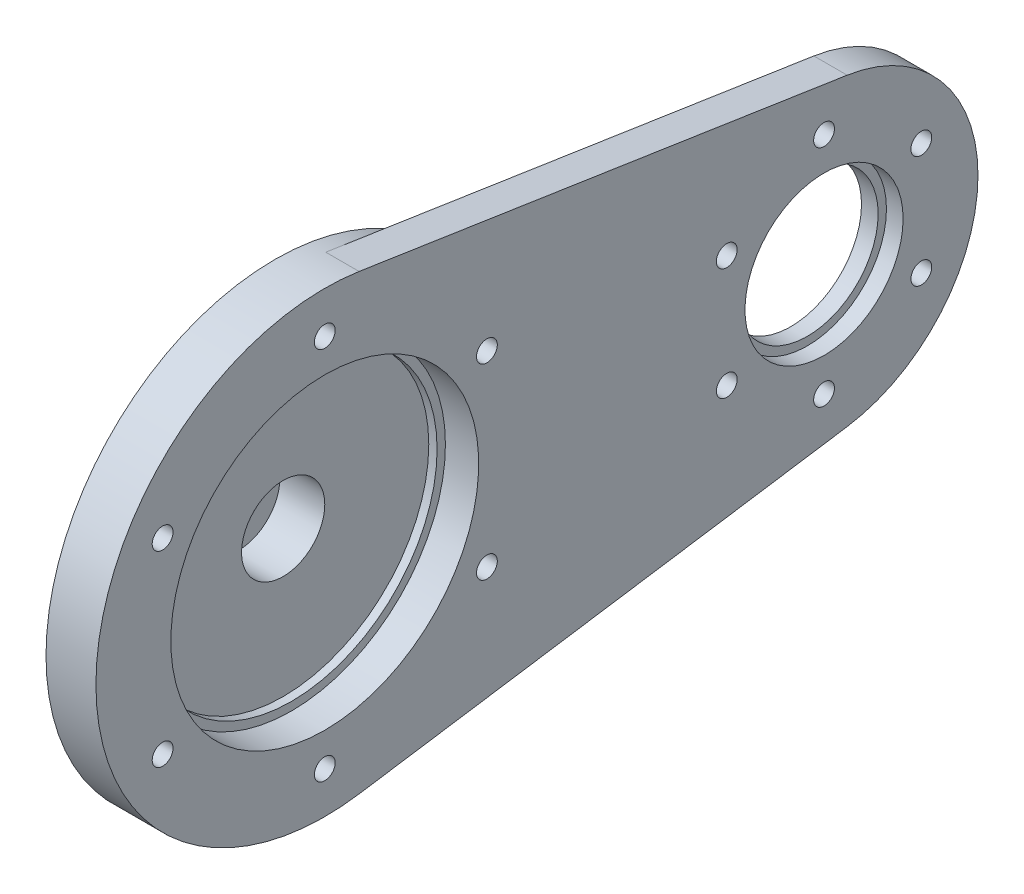
from build123d import *

# Parameters (mm, degrees)
SKETCH_3_R                   = 27.5
EXTRUDE_1_DEPTH              = 2
SKETCH_4_R                   = 27.5
SKETCH_4_R_2                 = 17.5
EXTRUDE_2_DEPTH              = 1
SKETCH_5_R                   = 27.5
SKETCH_5_R_2                 = 18.5
EXTRUDE_3_DEPTH              = 7
SKETCH_6_R                   = 27.5
SKETCH_6_R_2                 = 17.5
EXTRUDE_4_DEPTH              = 2
EXTRUDE_5_DEPTH              = 9
SKETCH_11_R                  = 8.5
CUT_EXTRUDE_3_DEPTH          = 111
SKETCH_12_R                  = 9.5
CUT_EXTRUDE_4_DEPTH          = 2.5
SKETCH_13_R                  = 9.5
EXTRUDE_6_DEPTH              = 5
SKETCH_17_W                  = 17.714059585
SKETCH_17_H                  = 64.604217311
CUT_EXTRUDE_5_DEPTH          = 1111
HOLE_WIZARD_M3_1_D           = 2.5
PATTERN_CIRCULAR_2_COUNT     = 6
HOLE_WIZARD_M3_2_D           = 2.5
PATTERN_CIRCULAR_3_COUNT     = 6
SKETCH_26_R                  = 27.5
SKETCH_26_R_2                = 25
CUT_EXTRUDE_6_DEPTH          = 1
FILLET_1_R                   = 0.1
PATTERN_CIRCULAR_4_COUNT     = 3
HOLE_WIZARD_M5_1_D           = 5.3
HOLE_WIZARD_M5_1_CBORE_D     = 10
HOLE_WIZARD_M5_1_CBORE_DEPTH = 5.4


with BuildPart() as part:
    # 스케치3 → 보스-돌출1 (new body)
    with BuildSketch(Plane(origin=(0, 0, 0), x_dir=(0, 0, -1), z_dir=(1, 0, 0))):
        Circle(SKETCH_3_R)
    extrude(amount=EXTRUDE_1_DEPTH)

    # 스케치4 → 보스-돌출2 (add)
    with BuildSketch(Plane(origin=(2, 0, 0), x_dir=(0, 0, -1), z_dir=(1, 0, 0))):
        Circle(SKETCH_4_R)
        Circle(SKETCH_4_R_2, mode=Mode.SUBTRACT)
    extrude(amount=EXTRUDE_2_DEPTH)

    # 스케치5 → 보스-돌출3 (add)
    with BuildSketch(Plane(origin=(3, 0, 0), x_dir=(0, 0, -1), z_dir=(1, 0, 0))):
        Circle(SKETCH_5_R)
        Circle(SKETCH_5_R_2, mode=Mode.SUBTRACT)
    extrude(amount=EXTRUDE_3_DEPTH)

    # 스케치6 → 보스-돌출4 (add)
    with BuildSketch(Plane(origin=(10, 0, 0), x_dir=(0, 0, -1), z_dir=(1, 0, 0))):
        Circle(SKETCH_6_R)
        Circle(SKETCH_6_R_2, mode=Mode.SUBTRACT)
    extrude(amount=EXTRUDE_4_DEPTH)

    # 스케치10 → 보스-돌출5 (add)
    with BuildSketch(Plane(origin=(12, 0, 0), x_dir=(0, 0, -1), z_dir=(1, 0, 0))):
        with BuildLine():
            Line((4.125, 27.188864908), (62.775, 18.290690938))
            ThreePointArc((62.775, 18.290690938), (78.5, 0), (62.775, -18.290690938))
            Line((62.775, -18.290690938), (4.125, -27.188864908))
            ThreePointArc((4.125, -27.188864908), (27.5, 0), (4.125, 27.188864908))
        make_face()
    extrude(amount=-EXTRUDE_5_DEPTH)

    # 스케치11 → 컷-돌출3 (cut, symmetric)
    with BuildSketch(Plane(origin=(7.5, 0, 0), x_dir=(0, 0, -1), z_dir=(1, 0, 0))):
        with Locations((60, 0)):
            Circle(SKETCH_11_R)
    extrude(amount=CUT_EXTRUDE_3_DEPTH, both=True, mode=Mode.SUBTRACT)

    # 스케치12 → 컷-돌출4 (cut, symmetric)
    with BuildSketch(Plane(origin=(7.5, 0, 0), x_dir=(0, 0, -1), z_dir=(1, 0, 0))):
        with Locations((60, 0)):
            Circle(SKETCH_12_R)
    extrude(amount=CUT_EXTRUDE_4_DEPTH, both=True, mode=Mode.SUBTRACT)

    # 스케치13 → 보스-돌출6 (add)
    with BuildSketch(Plane.ZY):
        Circle(SKETCH_13_R)
    extrude(amount=EXTRUDE_6_DEPTH)

    # 스케치17 → 컷-돌출5 (cut, symmetric)
    with BuildSketch(Plane.XY):
        with Locations((15.857029793, -1.852450676)):
            Rectangle(SKETCH_17_W, SKETCH_17_H)
    extrude(amount=CUT_EXTRUDE_5_DEPTH, both=True, mode=Mode.SUBTRACT)

    # Hole Wizard M3 _ _ _ _1 (through all)
    with Locations(Plane(origin=(7, 0, 0), x_dir=(0, 0, -1), z_dir=(1, 0, 0))):
        with Locations((0, 22.5)):
            hole_wizard_m3_1 = Hole(HOLE_WIZARD_M3_1_D / 2)

    # 원형 패턴2: Hole Wizard M3 _ _ _ _1 ×6 about axis
    pattern_circular_2_axis = Axis((0, 0, 0), (1, 0, 0))
    for i in range(1, PATTERN_CIRCULAR_2_COUNT):
        add(hole_wizard_m3_1.rotate(pattern_circular_2_axis, i * 360 / PATTERN_CIRCULAR_2_COUNT), mode=Mode.SUBTRACT)

    # M3 탭을 위한 탭 드릴2 (through all)
    with Locations(Plane(origin=(7, 0, 0), x_dir=(0, 0, -1), z_dir=(1, 0, 0))):
        with Locations((60, 13.5)):
            hole_wizard_m3_2 = Hole(HOLE_WIZARD_M3_2_D / 2)

    # 원형 패턴3: M3 탭을 위한 탭 드릴2 ×6 about axis
    pattern_circular_3_axis = Axis((0, 0, -60), (1, 0, 0))
    for i in range(1, PATTERN_CIRCULAR_3_COUNT):
        add(hole_wizard_m3_2.rotate(pattern_circular_3_axis, i * 360 / PATTERN_CIRCULAR_3_COUNT), mode=Mode.SUBTRACT)

    # 스케치26 → 컷-돌출6 (cut)
    with BuildSketch(Plane.ZY):
        Circle(SKETCH_26_R)
        Circle(SKETCH_26_R_2, mode=Mode.SUBTRACT)
    extrude(amount=-CUT_EXTRUDE_6_DEPTH, mode=Mode.SUBTRACT)

    # 필렛1
    fillet_1_edges = [part.edges().sort_by_distance(p)[0] for p in [
        (0, 0, -9.5),
        (-5, 0, -9.5),
    ]]
    fillet(fillet_1_edges, radius=FILLET_1_R)

    # 스케치29 → Ø3.0mm 맞춤핀 구멍1 (revolve, cut)
    with BuildSketch(Plane(origin=(-5, -7, 0), x_dir=(0, 0, 1), z_dir=(0, 1, 0))):
        Polygon((0, 0), (0, 5.901290929), (1.5, 5), (1.5, 0), align=None)
    f_3_0mm_1 = revolve(axis=Axis((-11.35, -7, 0), (1, 0, 0)), mode=Mode.SUBTRACT)

    # 원형 패턴4: Ø3.0mm 맞춤핀 구멍1 ×3 about axis
    pattern_circular_4_axis = Axis((0, 0, 0), (1, 0, 0))
    for i in range(1, PATTERN_CIRCULAR_4_COUNT):
        add(f_3_0mm_1.rotate(pattern_circular_4_axis, i * 360 / PATTERN_CIRCULAR_4_COUNT), mode=Mode.SUBTRACT)

    # M5 육각 소켓 머리 캡 나사용 카운터보어1 (through all)
    with Locations(Plane(origin=(2, 0, 0), x_dir=(0, 0, -1), z_dir=(1, 0, 0))):
        with Locations((0, 0)):
            CounterBoreHole(HOLE_WIZARD_M5_1_D / 2, HOLE_WIZARD_M5_1_CBORE_D / 2, HOLE_WIZARD_M5_1_CBORE_DEPTH)


solid = part.part
